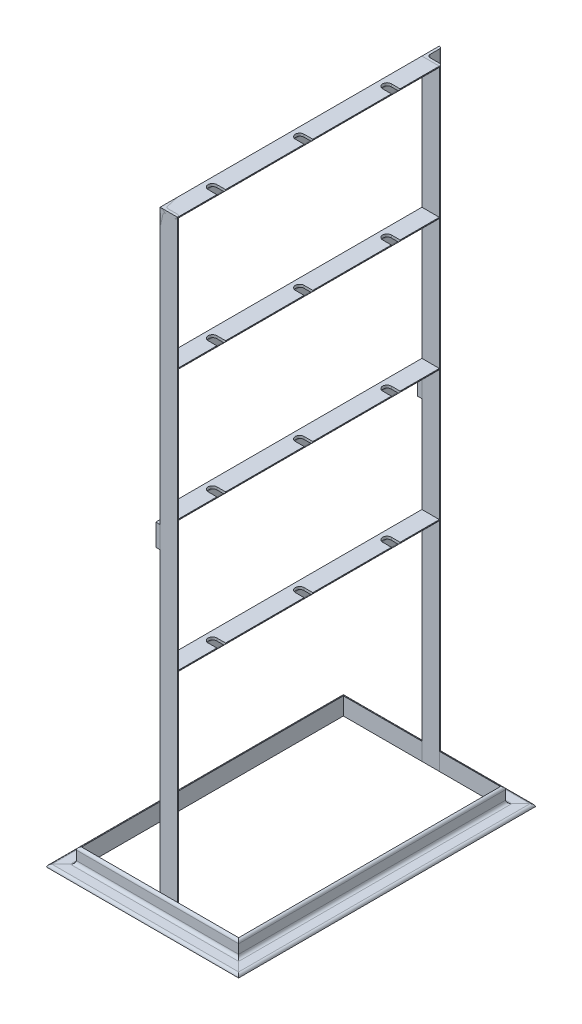
from build123d import *

# Parameters (mm, degrees)
STRUCTURAL_MEMBER1_DEPTH      = 329.284271247
STRUCTURAL_MEMBER1_DEPTH_BACK = 29.284271247
STRUCTURAL_MEMBER1_2_DEPTH    = 238.568542495
STRUCTURAL_MEMBER1_3_DEPTH    = 358.568542495
STRUCTURAL_MEMBER1_4_DEPTH    = 238.568542495
STRUCTURAL_MEMBER2_DEPTH      = 700
STRUCTURAL_MEMBER2_2_DEPTH    = 700
STRUCTURAL_MEMBER3_DEPTH      = 300
STRUCTURAL_MEMBER3_2_DEPTH    = 300
STRUCTURAL_MEMBER3_3_DEPTH    = 300
STRUCTURAL_MEMBER3_4_DEPTH    = 300
CUT_EXTRUDE1_DEPTH            = 512
LPATTERN1_COUNT               = 3
LPATTERN1_PITCH               = 100
SKETCH24_W                    = 20
SKETCH24_H                    = 25
BOSS_EXTRUDE2_DEPTH           = 5
BOSS_EXTRUDE2_2_DEPTH         = 5


with BuildPart() as part:
    # Sketch1 → Structural Member1 (new, two sides)
    with BuildSketch(Plane(origin=(90, 0, -150), x_dir=(1, 0, 0), z_dir=(0, 0, 1))) as structural_member1_sk:
        with BuildLine():
            Line((0, 0), (0, 20))
            ThreePointArc((0, 20), (2.121320344, 19.121320344), (3, 17))
            Line((3, 17), (3, 6.5))
            ThreePointArc((3, 6.5), (4.025126266, 4.025126266), (6.5, 3))
            Line((6.5, 3), (17, 3))
            ThreePointArc((17, 3), (19.121320344, 2.121320344), (20, 0))
            Line((20, 0), (0, 0))
        make_face()
    extrude(amount=STRUCTURAL_MEMBER1_DEPTH)
    extrude(structural_member1_sk.sketch, amount=-STRUCTURAL_MEMBER1_DEPTH_BACK)

    # Structural Member1 mitre 1
    split(bisect_by=Plane(origin=(90, 0, -150), x_dir=(0, 1, 0), z_dir=(0.707106781, 0, 0.707106781)), keep=Keep.TOP)

    # Structural Member1 mitre 2
    split(bisect_by=Plane(origin=(90, 0, 150), x_dir=(0, 1, 0), z_dir=(0.707106781, 0, -0.707106781)), keep=Keep.TOP)


with BuildPart() as body_2:
    # Sketch1 on segment 2 (carried to segment 2) → Structural Member1 2 (new body)
    with BuildSketch(Plane(origin=(119.284271247, 0, 150), x_dir=(0, 0, 1), z_dir=(-1, 0, 0))):
        with BuildLine():
            Line((0, 0), (0, 20))
            ThreePointArc((0, 20), (2.121320344, 19.121320344), (3, 17))
            Line((3, 17), (3, 6.5))
            ThreePointArc((3, 6.5), (4.025126266, 4.025126266), (6.5, 3))
            Line((6.5, 3), (17, 3))
            ThreePointArc((17, 3), (19.121320344, 2.121320344), (20, 0))
            Line((20, 0), (0, 0))
        make_face()
    extrude(amount=STRUCTURAL_MEMBER1_2_DEPTH)

    # Structural Member1 2 mitre 1
    split(bisect_by=Plane(origin=(-90, 0, 150), x_dir=(0, 1, 0), z_dir=(0.707106781, 0, 0.707106781)), keep=Keep.TOP)

    # Structural Member1 2 mitre 2
    split(bisect_by=Plane(origin=(90, 0, 150), x_dir=(0, -1, 0), z_dir=(-0.707106781, 0, 0.707106781)), keep=Keep.TOP)


with BuildPart() as body_3:
    # Sketch1 on segment 3 (carried to segment 3) → Structural Member1 3 (new body)
    with BuildSketch(Plane(origin=(-90, 0, 179.284271247), x_dir=(-1, 0, 0), z_dir=(0, 0, -1))):
        with BuildLine():
            Line((0, 0), (0, 20))
            ThreePointArc((0, 20), (2.121320344, 19.121320344), (3, 17))
            Line((3, 17), (3, 6.5))
            ThreePointArc((3, 6.5), (4.025126266, 4.025126266), (6.5, 3))
            Line((6.5, 3), (17, 3))
            ThreePointArc((17, 3), (19.121320344, 2.121320344), (20, 0))
            Line((20, 0), (0, 0))
        make_face()
    extrude(amount=STRUCTURAL_MEMBER1_3_DEPTH)

    # Structural Member1 3 mitre 1
    split(bisect_by=Plane(origin=(-90, 0, -150), x_dir=(0, -1, 0), z_dir=(-0.707106781, 0, 0.707106781)), keep=Keep.TOP)

    # Structural Member1 3 mitre 2
    split(bisect_by=Plane(origin=(-90, 0, 150), x_dir=(0, -1, 0), z_dir=(-0.707106781, 0, -0.707106781)), keep=Keep.TOP)


with BuildPart() as body_4:
    # Sketch1 on segment 4 (carried to segment 4) → Structural Member1 4 (new body)
    with BuildSketch(Plane(origin=(-119.284271247, 0, -150), x_dir=(0, 0, -1), z_dir=(1, 0, 0))):
        with BuildLine():
            Line((0, 0), (0, 20))
            ThreePointArc((0, 20), (2.121320344, 19.121320344), (3, 17))
            Line((3, 17), (3, 6.5))
            ThreePointArc((3, 6.5), (4.025126266, 4.025126266), (6.5, 3))
            Line((6.5, 3), (17, 3))
            ThreePointArc((17, 3), (19.121320344, 2.121320344), (20, 0))
            Line((20, 0), (0, 0))
        make_face()
    extrude(amount=STRUCTURAL_MEMBER1_4_DEPTH)

    # Structural Member1 4 mitre 1
    split(bisect_by=Plane(origin=(-90, 0, -150), x_dir=(0, 1, 0), z_dir=(0.707106781, 0, -0.707106781)), keep=Keep.TOP)

    # Structural Member1 4 mitre 2
    split(bisect_by=Plane(origin=(90, 0, -150), x_dir=(0, -1, 0), z_dir=(-0.707106781, 0, -0.707106781)), keep=Keep.TOP)


with BuildPart() as body_5:
    # Sketch11 → Structural Member2 (new body)
    with BuildSketch(Plane(origin=(0, 0, 150), x_dir=(1, 0, 0), z_dir=(0, 1, 0))):
        with BuildLine():
            Line((0, 0), (0, 20))
            ThreePointArc((0, 20), (2.121320344, 19.121320344), (3, 17))
            Line((3, 17), (3, 6.5))
            ThreePointArc((3, 6.5), (4.025126266, 4.025126266), (6.5, 3))
            Line((6.5, 3), (17, 3))
            ThreePointArc((17, 3), (19.121320344, 2.121320344), (20, 0))
            Line((20, 0), (0, 0))
        make_face()
    extrude(amount=STRUCTURAL_MEMBER2_DEPTH)


with BuildPart() as body_6:
    # Sketch11 on segment 2 (carried to segment 2) → Structural Member2 2 (new body)
    with BuildSketch(Plane(origin=(0, 0, -150), x_dir=(1, 0, 0), z_dir=(0, 1, 0))):
        with BuildLine():
            Line((0, 0), (0, 20))
            ThreePointArc((0, 20), (2.121320344, 19.121320344), (3, 17))
            Line((3, 17), (3, 6.5))
            ThreePointArc((3, 6.5), (4.025126266, 4.025126266), (6.5, 3))
            Line((6.5, 3), (17, 3))
            ThreePointArc((17, 3), (19.121320344, 2.121320344), (20, 0))
            Line((20, 0), (0, 0))
        make_face()
    extrude(amount=STRUCTURAL_MEMBER2_2_DEPTH)


with BuildPart() as body_7:
    # Sketch12 → Structural Member3 (new body)
    with BuildSketch(Plane(origin=(0, 700, 150), x_dir=(1, 0, 0), z_dir=(0, 0, -1))):
        with BuildLine():
            Line((0, 0), (0, 20))
            ThreePointArc((0, 20), (2.121320344, 19.121320344), (3, 17))
            Line((3, 17), (3, 6.5))
            ThreePointArc((3, 6.5), (4.025126266, 4.025126266), (6.5, 3))
            Line((6.5, 3), (17, 3))
            ThreePointArc((17, 3), (19.121320344, 2.121320344), (20, 0))
            Line((20, 0), (0, 0))
        make_face()
    extrude(amount=STRUCTURAL_MEMBER3_DEPTH)


with BuildPart() as body_8:
    # Sketch12 on segment 2 (carried to segment 2) → Structural Member3 2 (new body)
    with BuildSketch(Plane(origin=(0, 550, 150), x_dir=(1, 0, 0), z_dir=(0, 0, -1))):
        with BuildLine():
            Line((0, 0), (0, 20))
            ThreePointArc((0, 20), (2.121320344, 19.121320344), (3, 17))
            Line((3, 17), (3, 6.5))
            ThreePointArc((3, 6.5), (4.025126266, 4.025126266), (6.5, 3))
            Line((6.5, 3), (17, 3))
            ThreePointArc((17, 3), (19.121320344, 2.121320344), (20, 0))
            Line((20, 0), (0, 0))
        make_face()
    extrude(amount=STRUCTURAL_MEMBER3_2_DEPTH)


with BuildPart() as body_9:
    # Sketch12 on segment 3 (carried to segment 3) → Structural Member3 3 (new body)
    with BuildSketch(Plane(origin=(0, 400, 150), x_dir=(1, 0, 0), z_dir=(0, 0, -1))):
        with BuildLine():
            Line((0, 0), (0, 20))
            ThreePointArc((0, 20), (2.121320344, 19.121320344), (3, 17))
            Line((3, 17), (3, 6.5))
            ThreePointArc((3, 6.5), (4.025126266, 4.025126266), (6.5, 3))
            Line((6.5, 3), (17, 3))
            ThreePointArc((17, 3), (19.121320344, 2.121320344), (20, 0))
            Line((20, 0), (0, 0))
        make_face()
    extrude(amount=STRUCTURAL_MEMBER3_3_DEPTH)


with BuildPart() as body_10:
    # Sketch12 on segment 4 (carried to segment 4) → Structural Member3 4 (new body)
    with BuildSketch(Plane(origin=(0, 250, 150), x_dir=(1, 0, 0), z_dir=(0, 0, -1))):
        with BuildLine():
            Line((0, 0), (0, 20))
            ThreePointArc((0, 20), (2.121320344, 19.121320344), (3, 17))
            Line((3, 17), (3, 6.5))
            ThreePointArc((3, 6.5), (4.025126266, 4.025126266), (6.5, 3))
            Line((6.5, 3), (17, 3))
            ThreePointArc((17, 3), (19.121320344, 2.121320344), (20, 0))
            Line((20, 0), (0, 0))
        make_face()
    extrude(amount=STRUCTURAL_MEMBER3_4_DEPTH)


with BuildPart() as cut_extrude1_tool:
    # Sketch23 → Cut-Extrude1 (new body)
    with BuildSketch(Plane(origin=(0, 700, 0), x_dir=(1, 0, 0), z_dir=(0, 1, 0))):
        with BuildLine():
            Line((10, -105), (20, -105))
            Line((20, -105), (20, -95))
            Line((20, -95), (10, -95))
            ThreePointArc((10, -95), (5, -100), (10, -105))
        make_face()
    cut_extrude1 = extrude(amount=-CUT_EXTRUDE1_DEPTH)


with BuildPart() as body_7_1:
    add(body_7.part)

    # Cut-Extrude1: cut by cut_extrude1_tool
    add(cut_extrude1_tool.part, mode=Mode.SUBTRACT)


with BuildPart() as body_8_1:
    add(body_8.part)

    # Cut-Extrude1: cut by cut_extrude1_tool
    add(cut_extrude1_tool.part, mode=Mode.SUBTRACT)


with BuildPart() as body_9_1:
    add(body_9.part)

    # Cut-Extrude1: cut by cut_extrude1_tool
    add(cut_extrude1_tool.part, mode=Mode.SUBTRACT)


with BuildPart() as body_10_1:
    add(body_10.part)

    # Cut-Extrude1: cut by cut_extrude1_tool
    add(cut_extrude1_tool.part, mode=Mode.SUBTRACT)


with BuildPart() as lpattern1_tool:
    # LPattern1: Cut-Extrude1 ×3
    with Locations(*[(0, 0, -i * LPATTERN1_PITCH) for i in range(1, LPATTERN1_COUNT)]):
        add(cut_extrude1)


with BuildPart() as body_7_2:
    add(body_7_1.part)

    # LPattern1: cut by lpattern1_tool
    add(lpattern1_tool.part, mode=Mode.SUBTRACT)


with BuildPart() as body_8_2:
    add(body_8_1.part)

    # LPattern1: cut by lpattern1_tool
    add(lpattern1_tool.part, mode=Mode.SUBTRACT)


with BuildPart() as body_9_2:
    add(body_9_1.part)

    # LPattern1: cut by lpattern1_tool
    add(lpattern1_tool.part, mode=Mode.SUBTRACT)


with BuildPart() as body_10_2:
    add(body_10_1.part)

    # LPattern1: cut by lpattern1_tool
    add(lpattern1_tool.part, mode=Mode.SUBTRACT)


with BuildPart() as body_11:
    # Sketch24 → Boss-Extrude2 (new body)
    with BuildSketch(Plane.ZY):
        with Locations((140, 372.5)):
            Rectangle(SKETCH24_W, SKETCH24_H)
    extrude(amount=BOSS_EXTRUDE2_DEPTH)


with BuildPart() as body_12:
    # Sketch24 → Boss-Extrude2 2 (new body)
    with BuildSketch(Plane.ZY):
        with Locations((-160, 372.5)):
            Rectangle(SKETCH24_W, SKETCH24_H)
    extrude(amount=BOSS_EXTRUDE2_2_DEPTH)


solid = Compound([part.part, body_2.part, body_3.part, body_4.part, body_5.part, body_6.part, body_7_2.part, body_8_2.part, body_9_2.part, body_10_2.part, body_11.part, body_12.part])
